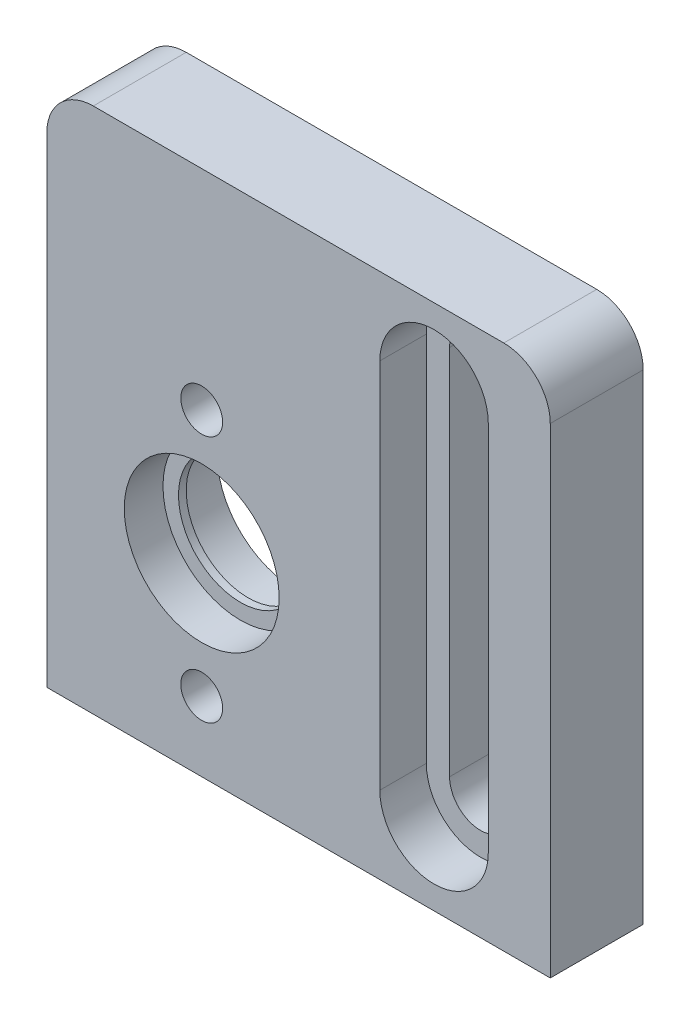
from build123d import *

# Parameters (mm, degrees)
SKIZZE1_W                                            = 65
SKIZZE1_H                                            = 34
SKIZZE1_R                                            = 9
SKIZZE1_R_2                                          = 4
AUFSATZ_LINEAR_AUSTRAGEN1_DEPTH                      = 3
SCHNITT_LINEAR_START                                 = 3
SKIZZE1_3_R                                          = 10.5
SCHNITT_LINEAR_AUSTRAGEN1_DEPTH                      = 5
SKIZZE1_4_R                                          = 5
SCHNITT_LINEAR_AUSTRAGEN2_DEPTH                      = 3
SCHNITT_LINEAR_AUSTRAGEN4_DEPTH                      = 7
SCHNITT_LINEAR_AUSTRAGEN5_DEPTH                      = 3
VERRUNDUNG1_R                                        = 3
M3_GEWINDEBOHRUNG1_D                                 = 2.5
M3_GEWINDEBOHRUNG1_DEPTH                             = 7
M3_GEWINDEBOHRUNG1_TIP                               = 0.751075774
M3_GEWINDEBOHRUNG2_D                                 = 2.5
M3_GEWINDEBOHRUNG2_DEPTH                             = 7.5
M3_GEWINDEBOHRUNG2_TIP                               = 0.751075774
SKIZZE6_3_OUTSIDE_W                                  = 81.72
SKIZZE6_3_OUTSIDE_H                                  = 50.72
SKIZZE6_3_OUTSIDE_W_2                                = 32.5
SKIZZE6_3_OUTSIDE_H_2                                = 34
NUR_ANTRIEB_DEPTH                                    = 7
VERRUNDUNG3_R                                        = 3
SKIZZE7_R                                            = 5
SCHNITT_LINEAR_AUSTRAGEN3_DEPTH                      = 2.5
STIRNSENKUNG_F_R_M2_5_ZYLINDERSCHRAUBE_M_D           = 2.7
STIRNSENKUNG_F_R_M2_5_ZYLINDERSCHRAUBE_M_CBORE_D     = 5.5
STIRNSENKUNG_F_R_M2_5_ZYLINDERSCHRAUBE_M_CBORE_DEPTH = 1.8


with BuildPart() as part:
    # Skizze1 → Aufsatz-Linear austragen1 (new body, symmetric)
    with BuildSketch(Plane.XY):
        with Locations((0, 1.5)):
            Rectangle(SKIZZE1_W, SKIZZE1_H)
        with Locations((20.5, 0)):
            Circle(SKIZZE1_R, mode=Mode.SUBTRACT)
        with Locations((-22.5, -3)):
            Circle(SKIZZE1_R_2, mode=Mode.SUBTRACT)
    extrude(amount=AUFSATZ_LINEAR_AUSTRAGEN1_DEPTH, both=True)

    # Skizze1_3 → Schnitt-Linear austragen1 (cut)
    with BuildSketch(Plane.XY.offset(SCHNITT_LINEAR_START)):
        with Locations((20.5, 0)):
            Circle(SKIZZE1_3_R)
    extrude(amount=-SCHNITT_LINEAR_AUSTRAGEN1_DEPTH, mode=Mode.SUBTRACT)

    # Skizze1_4 → Schnitt-Linear austragen2 (cut)
    with BuildSketch(Plane.XY.offset(SCHNITT_LINEAR_START)):
        with Locations((-22.5, -3)):
            Circle(SKIZZE1_4_R)
    extrude(amount=-SCHNITT_LINEAR_AUSTRAGEN2_DEPTH, mode=Mode.SUBTRACT)

    # Skizze11 → Schnitt-Linear austragen4 (cut, through all)
    with BuildSketch(Plane(origin=(0, 0, -3), x_dir=(-1, 0, 0), z_dir=(0, 0, -1))):
        with BuildLine():
            Line((9.5, 13.5), (9.5, -10.5))
            ThreePointArc((9.5, -10.5), (7.5, -12.5), (5.5, -10.5))
            Line((5.5, -10.5), (5.5, 13.5))
            ThreePointArc((5.5, 13.5), (7.5, 15.5), (9.5, 13.5))
        make_face()
    extrude(amount=-SCHNITT_LINEAR_AUSTRAGEN4_DEPTH, mode=Mode.SUBTRACT)

    # Skizze11_4 → Schnitt-Linear austragen5 (cut)
    with BuildSketch(Plane(origin=(0, 0, -3), x_dir=(-1, 0, 0), z_dir=(0, 0, -1))):
        with BuildLine():
            Line((11, 13.5), (11, -10.5))
            ThreePointArc((11, -10.5), (7.5, -14), (4, -10.5))
            Line((4, -10.5), (4, 13.5))
            ThreePointArc((4, 13.5), (7.5, 17), (11, 13.5))
        make_face()
    extrude(amount=-SCHNITT_LINEAR_AUSTRAGEN5_DEPTH, mode=Mode.SUBTRACT)

    # Verrundung1
    verrundung1_edges = [part.edges().sort_by_distance(p)[0] for p in [
        (-32.5, 18.5, 0),
        (32.5, 18.5, 0),
    ]]
    fillet(verrundung1_edges, radius=VERRUNDUNG1_R)

    # M3 Gewindebohrung1
    with Locations(Plane(origin=(-30, -15.5, -6.25), x_dir=(-1, 0, 0), z_dir=(0, -1, 0))):
        with Locations((-56.5, -6.75), (-1.5, -6.75), (-44.5, -6.75), (-13.5, -6.75)):
            Hole(M3_GEWINDEBOHRUNG1_D / 2, depth=M3_GEWINDEBOHRUNG1_DEPTH)
            with Locations((0, 0, -(M3_GEWINDEBOHRUNG1_DEPTH + M3_GEWINDEBOHRUNG1_TIP / 2))):  # 118° drill point
                Cone(0, M3_GEWINDEBOHRUNG1_D / 2, M3_GEWINDEBOHRUNG1_TIP, mode=Mode.SUBTRACT)

    # M3 Gewindebohrung2
    with Locations(Plane(origin=(0, 18.5, 0), x_dir=(1, 0, 0), z_dir=(0, 1, 0))):
        with Locations((20.5, 0)):
            Hole(M3_GEWINDEBOHRUNG2_D / 2, depth=M3_GEWINDEBOHRUNG2_DEPTH)
            with Locations((0, 0, -(M3_GEWINDEBOHRUNG2_DEPTH + M3_GEWINDEBOHRUNG2_TIP / 2))):  # 118° drill point
                Cone(0, M3_GEWINDEBOHRUNG2_D / 2, M3_GEWINDEBOHRUNG2_TIP, mode=Mode.SUBTRACT)


with BuildPart() as body_2:
    # Spiegeln1: mirrored copy
    add(part.part.mirror(Plane.XY.offset(3)))

    # Skizze6_3 outside → Nur Antrieb (cut, through all)
    with BuildSketch(Plane(origin=(0, 0, 3), x_dir=(-1, 0, 0), z_dir=(0, 0, -1))):
        with Locations((0, 1.5)):
            Rectangle(SKIZZE6_3_OUTSIDE_W, SKIZZE6_3_OUTSIDE_H)
        with Locations((16.25, 1.5)):
            Rectangle(SKIZZE6_3_OUTSIDE_W_2, SKIZZE6_3_OUTSIDE_H_2, mode=Mode.SUBTRACT)
    extrude(amount=-NUR_ANTRIEB_DEPTH, mode=Mode.SUBTRACT)

    # Verrundung3
    verrundung3_edges = [body_2.edges().sort_by_distance(p)[0] for p in [
        (0, 18.5, 6),
    ]]
    fillet(verrundung3_edges, radius=VERRUNDUNG3_R)

    # Skizze7 → Schnitt-Linear austragen3 (cut)
    with BuildSketch(Plane(origin=(0, 0, 9), x_dir=(-1, 0, 0), z_dir=(0, 0, -1))):
        with Locations((22.5, -3)):
            Circle(SKIZZE7_R)
    extrude(amount=SCHNITT_LINEAR_AUSTRAGEN3_DEPTH, mode=Mode.SUBTRACT)

    # Stirnsenkung für  M2.5 Zylinderschraube mit Schlitz/Kreuzschlitz1 (through all)
    with Locations(Plane(origin=(6.813962519, -2.610238453, 3), x_dir=(1, 0, 0), z_dir=(0, 0, -1))):
        with Locations((-29.313962519, -7.610238453), (-29.313962519, 8.389761547)):
            CounterBoreHole(STIRNSENKUNG_F_R_M2_5_ZYLINDERSCHRAUBE_M_D / 2, STIRNSENKUNG_F_R_M2_5_ZYLINDERSCHRAUBE_M_CBORE_D / 2, STIRNSENKUNG_F_R_M2_5_ZYLINDERSCHRAUBE_M_CBORE_DEPTH)


solid = body_2.part
